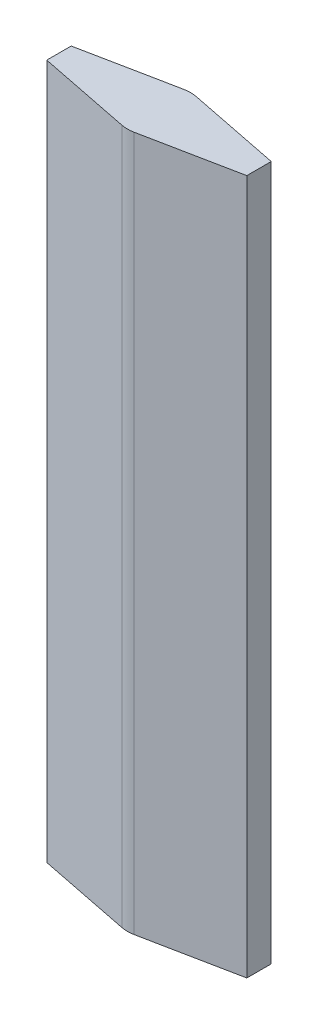
from build123d import *

# Parameters (mm, degrees)
EXTRUDE_1_DEPTH = 660


with BuildPart() as part:
    # 草图5 → 凸台-拉伸1 (new body, symmetric)
    with BuildSketch(Plane(origin=(0, 0, 0), x_dir=(1, 0, 0), z_dir=(0, 1, 0))):
        with BuildLine():
            Line((190, 0), (190, -23.210187215))
            Line((190, -23.210187215), (11.76, -58.836233734))
            ThreePointArc((11.76, -58.836233734), (0, -60), (-11.76, -58.836233734))
            Line((-11.76, -58.836233734), (-190, -23.210187215))
            Line((-190, -23.210187215), (-190, 0))
            Line((-190, 0), (-190, 23.210187215))
            Line((-190, 23.210187215), (-11.759999967, 58.836233741))
            ThreePointArc((-11.759999967, 58.836233741), (1.7e-08, 60), (11.76, 58.836233734))
            Line((11.76, 58.836233734), (190, 23.210187215))
            Line((190, 23.210187215), (190, 0))
        make_face()
    extrude(amount=EXTRUDE_1_DEPTH, both=True)


solid = part.part
